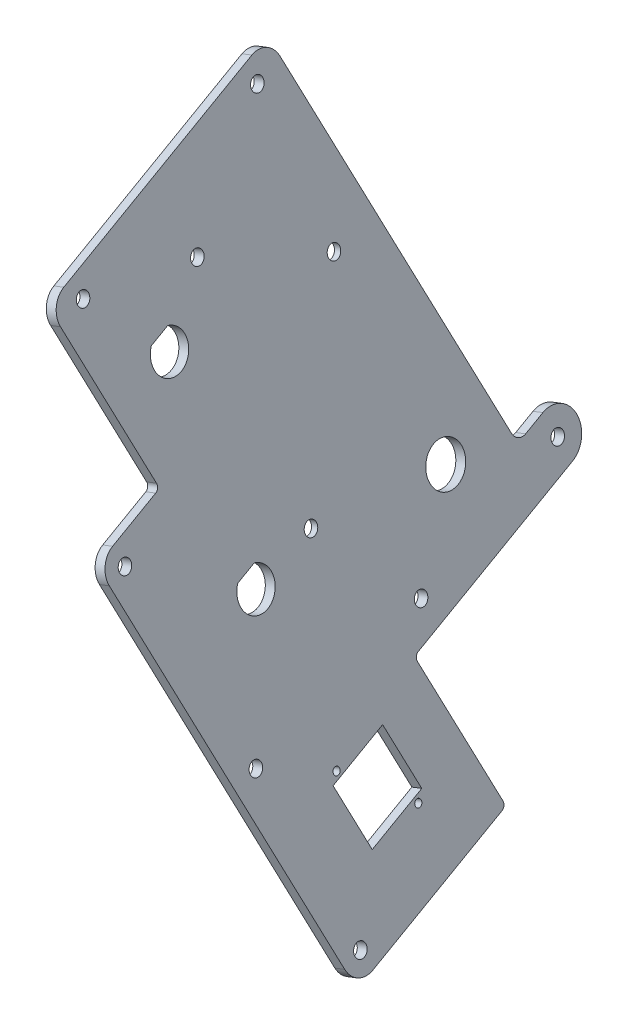
from build123d import *

# Parameters (mm, degrees)
BOSS_EXTRUDE1_DEPTH                               = 3.175
F_6_CLEARANCE_HOLE2_D                             = 4.3053
CUT_EXTRUDE1_DEPTH                                = 75.708255191
CUT_EXTRUDE11_DEPTH                               = 75.708255191
SKETCH112_R                                       = 6.35
CUT_EXTRUDE13_DEPTH                               = 75.708255191
CSK_FOR_6_FLAT_HEAD_MACHINE_SCREW_100_D           = 4.3053
CSK_FOR_6_FLAT_HEAD_MACHINE_SCREW_100_CSINK_D     = 7.0866
CSK_FOR_6_FLAT_HEAD_MACHINE_SCREW_100_CSINK_ANGLE = 100
F_2_CLEARANCE_HOLE1_D                             = 2.2606
F_2_CLEARANCE_HOLE1_DEPTH                         = 3.175


with BuildPart() as part:
    # Sketch2 → Boss-Extrude1 (new body)
    with BuildSketch(Plane(origin=(-64.088304417, -22.345630777, 3.470722632), x_dir=(-0.153926818, 0.29499983, -0.943017304), z_dir=(0.943017304, 0.328801279, -0.051069404))):
        with BuildLine():
            Line((-121.846755419, -165.728170273), (-69.459255419, -165.728170273))
            ThreePointArc((-69.459255419, -165.728170273), (-68.336723403, -165.263202289), (-67.871755419, -164.140670273))
            Line((-67.871755419, -164.140670273), (-67.871755419, -120.325670273))
            ThreePointArc((-67.871755419, -120.325670273), (-67.406787434, -119.203138258), (-66.284255419, -118.738170273))
            Line((-66.284255419, -118.738170273), (-3.736755419, -118.738170273))
            ThreePointArc((-3.736755419, -118.738170273), (3.883244581, -111.118170273), (-3.736755419, -103.498170273))
            Line((-3.736755419, -103.498170273), (-10.721755419, -103.498170273))
            ThreePointArc((-10.721755419, -103.498170273), (-12.966819449, -102.568234304), (-13.896755419, -100.323170273))
            Line((-13.896755419, -100.323170273), (-13.896755419, 18.421829727))
            ThreePointArc((-13.896755419, 18.421829727), (-15.756627358, 22.911957787), (-20.246755419, 24.771829727))
            Line((-20.246755419, 24.771829727), (-96.446755419, 24.771829727))
            ThreePointArc((-96.446755419, 24.771829727), (-100.936883479, 22.911957787), (-102.796755419, 18.421829727))
            Line((-102.796755419, 18.421829727), (-102.796755419, -30.790670273))
            ThreePointArc((-102.796755419, -30.790670273), (-103.261723403, -31.913202289), (-104.384255419, -32.378170273))
            Line((-104.384255419, -32.378170273), (-121.846755419, -32.378170273))
            ThreePointArc((-121.846755419, -32.378170273), (-126.336883479, -34.238042213), (-128.196755419, -38.728170273))
            Line((-128.196755419, -38.728170273), (-128.196755419, -159.378170273))
            ThreePointArc((-128.196755419, -159.378170273), (-126.336883479, -163.868298334), (-121.846755419, -165.728170273))
        make_face()
    extrude(amount=-BOSS_EXTRUDE1_DEPTH)

    # #6 Clearance Hole2 (through all)
    with Locations(Plane(origin=(-67.082384355, -23.389574839, 3.632867989), x_dir=(0.048222256, 0.016813625, 0.998695107), z_dir=(-0.943017304, -0.328801279, 0.051069404))):
        with Locations((94.496598047, -13.438577508), (27.821256, 9.809074133), (102.303221602, -76.684769209), (58.183274109, -19.607002634), (18.688641338, -122.850003783), (-33.055104908, -106.153526298), (79.375410017, -137.620951141), (62.581514662, -190.608465154)):
            Hole(F_6_CLEARANCE_HOLE2_D / 2)

    # Sketch11 → Cut-Extrude1 (cut, through all)
    with BuildSketch(Plane(origin=(-30.199339451, -118.769533988, 70.606372837), x_dir=(0.153926818, -0.29499983, 0.943017304), z_dir=(-0.943017304, -0.328801279, 0.051069404))):
        with BuildLine():
            Line((-5.443361979, 7.786170805), (1.218801886, 7.786170805))
            ThreePointArc((1.218801886, 7.786170805), (-2.112280046, -3.415229195), (-5.443361979, 7.786170805))
        make_face()
    extrude(amount=-CUT_EXTRUDE1_DEPTH, mode=Mode.SUBTRACT)

    # Sketch111 → Cut-Extrude11 (cut, through all)
    with BuildSketch(Plane(origin=(-50.471339887, -59.482551247, 77.984343899), x_dir=(0.153926818, -0.29499983, 0.943017304), z_dir=(-0.943017304, -0.328801279, 0.051069404))):
        with BuildLine():
            Line((-5.443361979, 7.786170805), (1.218801886, 7.786170805))
            ThreePointArc((1.218801886, 7.786170805), (-2.112280046, -3.415229195), (-5.443361979, 7.786170805))
        make_face()
    extrude(amount=-CUT_EXTRUDE11_DEPTH, mode=Mode.SUBTRACT)

    # Sketch112 → Cut-Extrude13 (cut, through all)
    with BuildSketch(Plane(origin=(-67.082384355, -23.389574839, 3.632867989), x_dir=(0.048222256, 0.016813625, 0.998695107), z_dir=(-0.943017304, -0.328801279, 0.051069404))):
        with Locations((1.528822601, -97.230139831)):
            Circle(SKETCH112_R)
        Polygon((51.631528484, -170.516238748), (32.684219053, -163.909891699), (39.290566102, -144.962582268), (58.237875533, -151.568929317), align=None)
    extrude(amount=-CUT_EXTRUDE13_DEPTH, mode=Mode.SUBTRACT)

    # CSK for #6 Flat Head Machine Screw (100)1 (through all)
    with Locations(Plane(origin=(-67.082384355, -23.389574839, 3.632867989), x_dir=(0.048222256, 0.016813625, 0.998695107), z_dir=(-0.943017304, -0.328801279, 0.051069404))):
        with Locations((18.106841092, -36.568198954), (45.444415988, -93.174400017)):
            CounterSinkHole(CSK_FOR_6_FLAT_HEAD_MACHINE_SCREW_100_D / 2, CSK_FOR_6_FLAT_HEAD_MACHINE_SCREW_100_CSINK_D / 2, counter_sink_angle=CSK_FOR_6_FLAT_HEAD_MACHINE_SCREW_100_CSINK_ANGLE)

    # #2 Clearance Hole1
    with Locations(Plane(origin=(-64.088304417, -22.345630777, 3.470722632), x_dir=(-0.048222256, -0.016813625, -0.998695107), z_dir=(0.943017304, 0.328801279, -0.051069404))):
        with Locations((-34.795660006, -166.629937328), (-56.12643458, -148.848883687)):
            Hole(F_2_CLEARANCE_HOLE1_D / 2, depth=F_2_CLEARANCE_HOLE1_DEPTH)


solid = part.part
